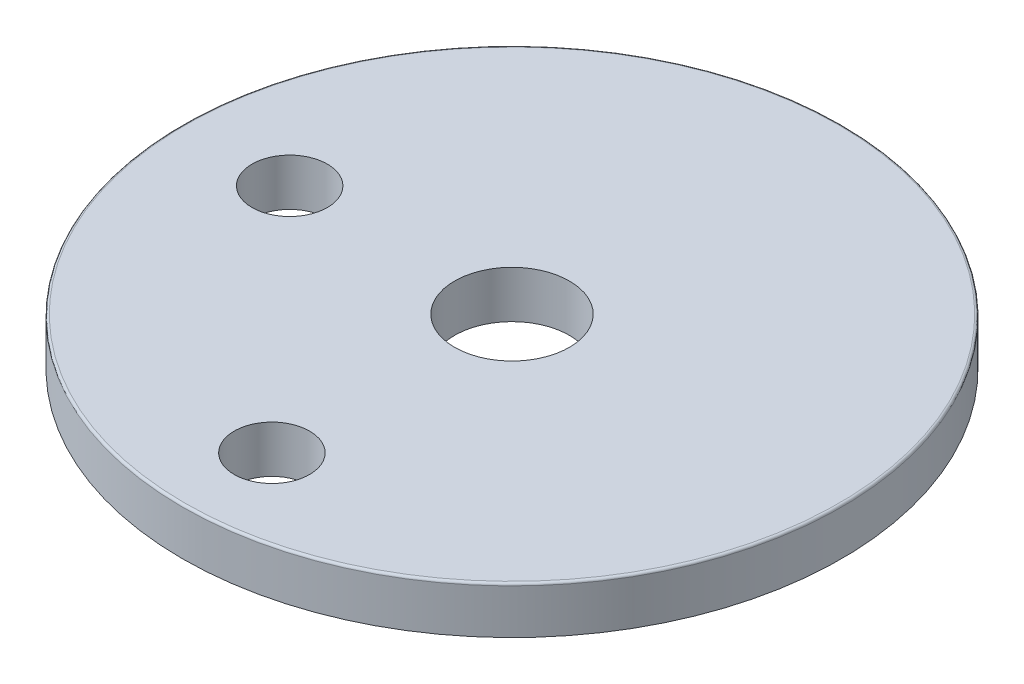
from build123d import *

# Parameters (mm, degrees)
SKETCH1_R           = 35
SKETCH1_R_2         = 6.1
SKETCH1_R_3         = 4
BOSS_EXTRUDE2_DEPTH = 5
FILLET1_R           = 0.25


with BuildPart() as part:
    # Sketch1 → Boss-Extrude2 (new body)
    with BuildSketch(Plane(origin=(0, 0, 0), x_dir=(1, 0, 0), z_dir=(0, 1, 0))):
        Circle(SKETCH1_R)
        Circle(SKETCH1_R_2, mode=Mode.SUBTRACT)
        with Locations((-23.61, 0)):
            Circle(SKETCH1_R_3, mode=Mode.SUBTRACT)
        with Locations((0, -25.5)):
            Circle(SKETCH1_R_3, mode=Mode.SUBTRACT)
    extrude(amount=BOSS_EXTRUDE2_DEPTH)

    # Fillet1
    fillet1_edges = [part.edges().sort_by_distance(p)[0] for p in [
        (-35, 5, 0),
    ]]
    fillet(fillet1_edges, radius=FILLET1_R)


solid = part.part
